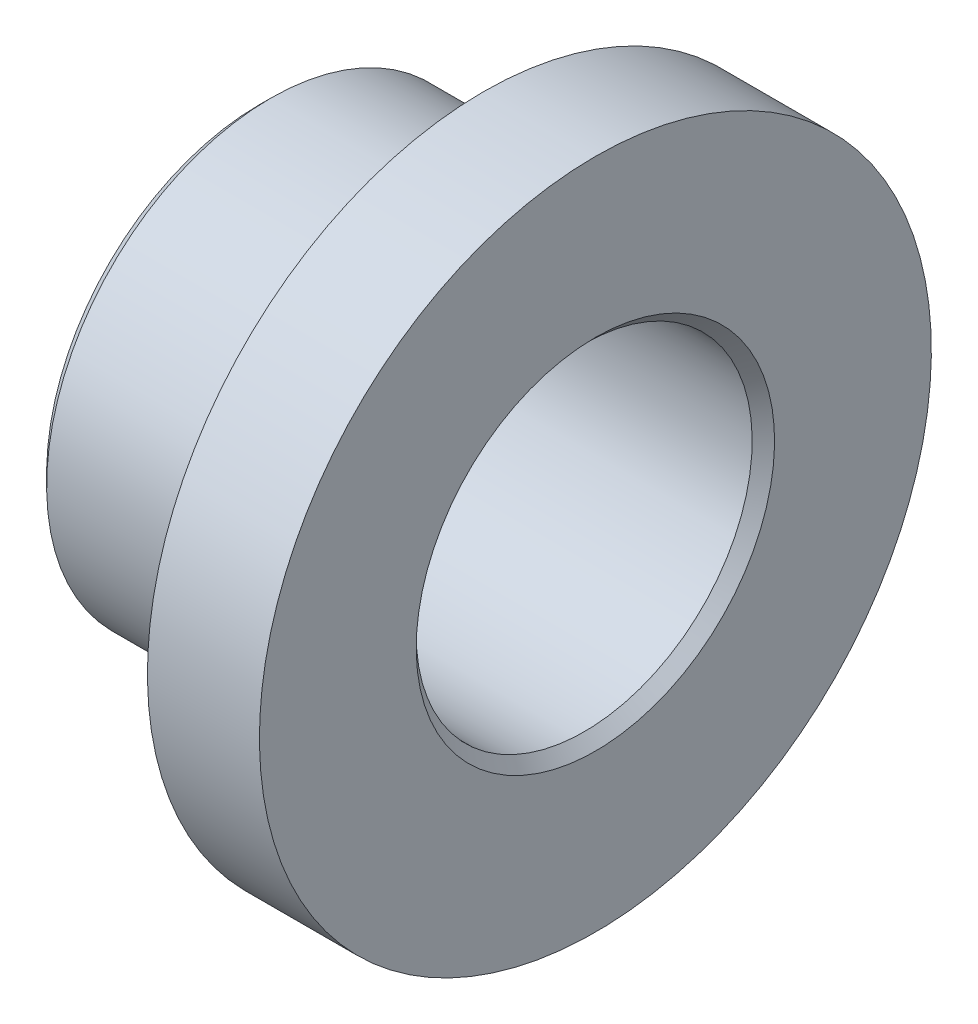
from build123d import *

# Parameters (mm, degrees)
ESQUISSE1_W     = 40
ESQUISSE1_H     = 10
CHANFREIN1_SIZE = 2


with BuildPart() as part:
    # Esquisse1 → Révolution1 (revolve)
    with BuildSketch(Plane.XY):
        with Locations((-20, 35)):
            Rectangle(ESQUISSE1_W, ESQUISSE1_H)
        Polygon((0, 40), (0, 30), (20, 30), (20, 60), (0, 60), align=None)
    revolve(axis=Axis((0, 0, 0), (-1, 0, 0)))

    # Chanfrein1
    chanfrein1_edges = [part.edges().sort_by_distance(p)[0] for p in [
        (-40, -40, 0),
        (20, -30, 0),
        (-40, -30, 0),
    ]]
    chamfer(chanfrein1_edges, length=CHANFREIN1_SIZE)


solid = part.part
